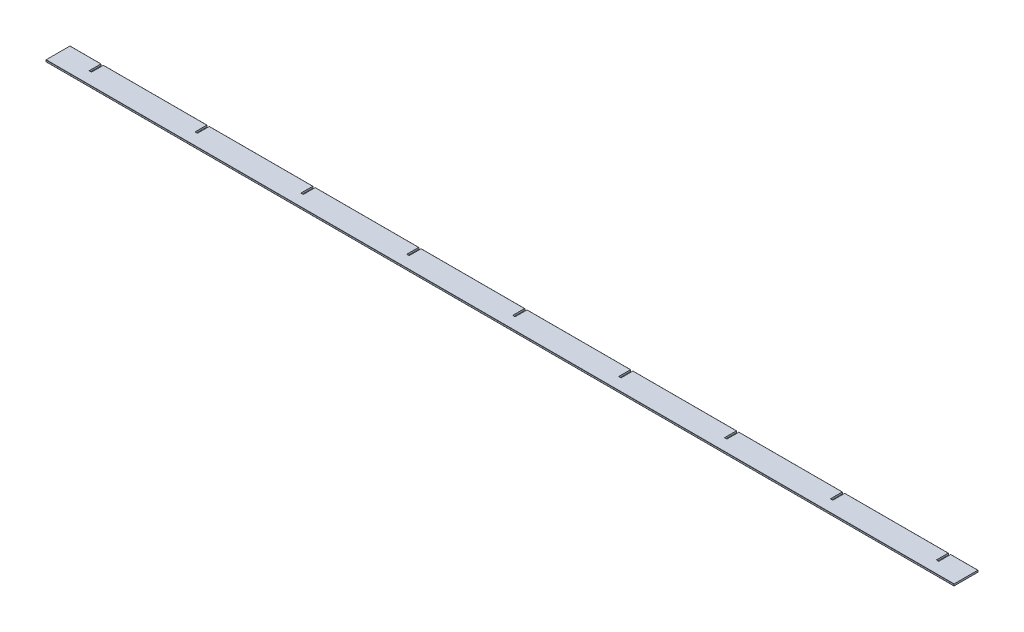
from build123d import *

# Parameters (mm, degrees)
BOSS_EXTRUDE1_DEPTH      = 1.5
BOSS_EXTRUDE1_DEPTH_BACK = 1.5
SKETCH1_W                = 1508
SKETCH1_H                = 40
FILLET1_R                = 0.35
SKETCH2_W                = 4
SKETCH2_H                = 20
CUT_EXTRUDE1_DEPTH       = 755.271171397


with BuildPart() as part:
    # Sketch1 → Boss-Extrude1 (new, two sides: drawn at the far end of the back side and taken through both)
    with BuildSketch(Plane(origin=(0, 0, 0), x_dir=(1, 0, 0), z_dir=(0, 1, 0)).offset(-BOSS_EXTRUDE1_DEPTH_BACK)):
        Rectangle(SKETCH1_W, SKETCH1_H)
    extrude(amount=BOSS_EXTRUDE1_DEPTH + BOSS_EXTRUDE1_DEPTH_BACK)

    # Fillet1
    fillet1_edges = [part.edges().sort_by_distance(p)[0] for p in [
        (0, -1.5, -20),
        (0, -1.5, 20),
        (0, 1.5, -20),
        (0, 1.5, 20),
    ]]
    fillet(fillet1_edges, radius=FILLET1_R)

    # Sketch2 → Cut-Extrude1 (cut, through all)
    with BuildSketch(Plane(origin=(0, 1.5, 0), x_dir=(1, 0, 0), z_dir=(0, 1, 0))):
        with Locations((530.92, 10)):
            Rectangle(SKETCH2_W, SKETCH2_H)
        with Locations((706.83, 10)):
            Rectangle(SKETCH2_W, SKETCH2_H)
        with Locations((355.01, 10)):
            Rectangle(SKETCH2_W, SKETCH2_H)
        with Locations((179.1, 10)):
            Rectangle(SKETCH2_W, SKETCH2_H)
        with Locations((3.19, 10)):
            Rectangle(SKETCH2_W, SKETCH2_H)
        with Locations((-172.72, 10)):
            Rectangle(SKETCH2_W, SKETCH2_H)
        with Locations((-348.63, 10)):
            Rectangle(SKETCH2_W, SKETCH2_H)
        with Locations((-524.54, 10)):
            Rectangle(SKETCH2_W, SKETCH2_H)
        with Locations((-700.45, 10)):
            Rectangle(SKETCH2_W, SKETCH2_H)
    extrude(amount=-CUT_EXTRUDE1_DEPTH, mode=Mode.SUBTRACT)


solid = part.part
